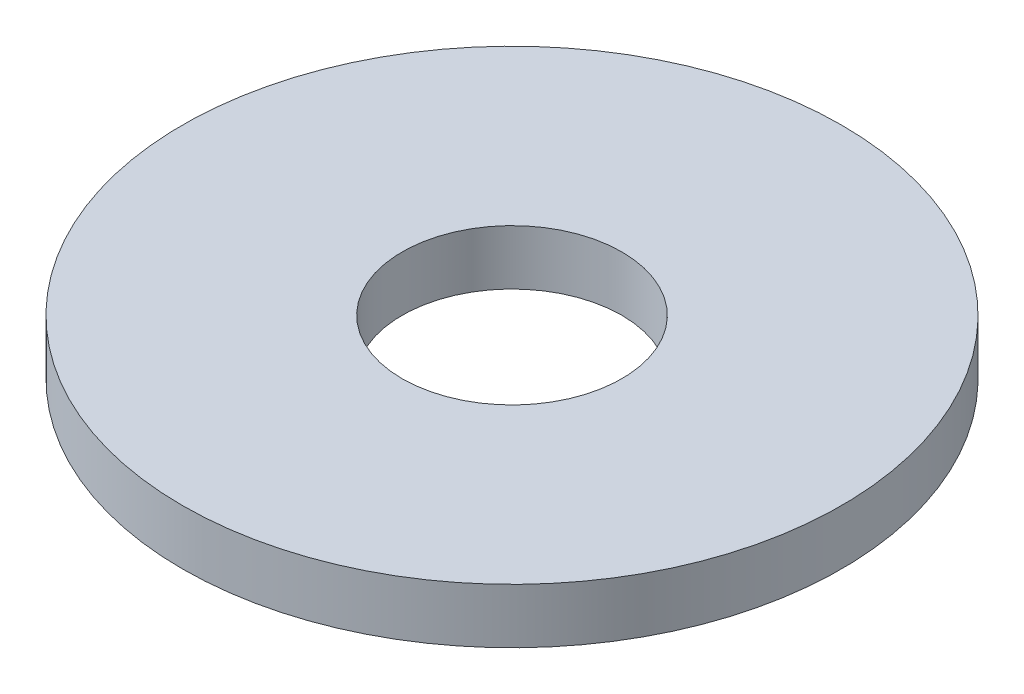
from build123d import *

# Parameters (mm, degrees)
SKETCH_1_R      = 6
SKETCH_1_R_2    = 2
EXTRUDE_1_DEPTH = 1


with BuildPart() as part:
    # Эскиз1 → Бобышка-Вытянуть1 (new body)
    with BuildSketch(Plane(origin=(0, 0, 0), x_dir=(1, 0, 0), z_dir=(0, 1, 0))):
        Circle(SKETCH_1_R)
        Circle(SKETCH_1_R_2, mode=Mode.SUBTRACT)
    extrude(amount=EXTRUDE_1_DEPTH)


solid = part.part
